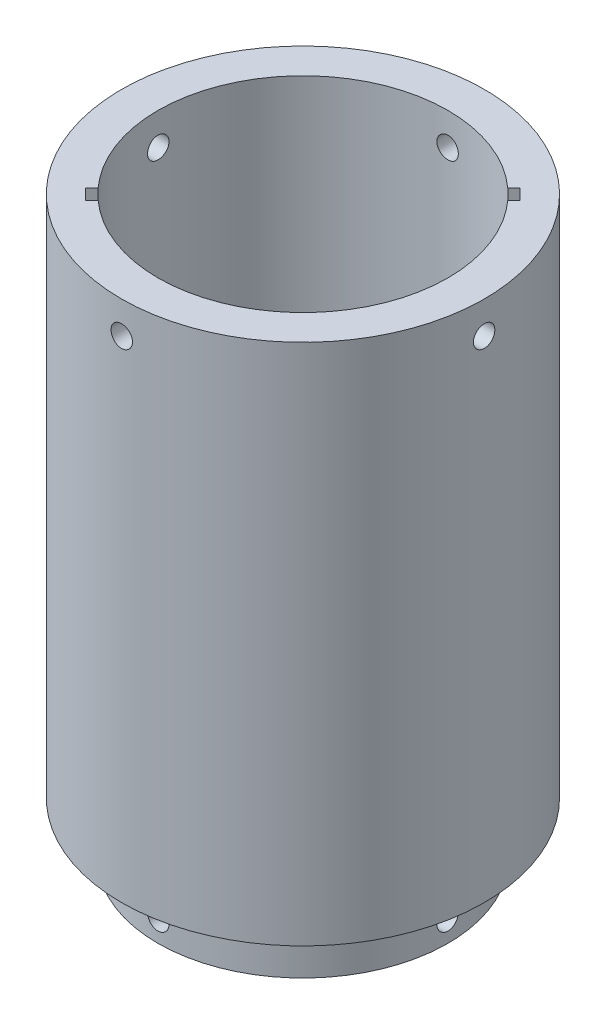
from build123d import *

# Parameters (mm, degrees)
SKETCH1_R               = 33.85
BOSS_EXTRUDE1_DEPTH     = 12.5
SKETCH2_R               = 2.5
CUT_EXTRUDE1_DEPTH      = 34.85
CUT_EXTRUDE1_DEPTH_BACK = 34.85
SKETCH3_R               = 2.5
CUT_EXTRUDE2_DEPTH      = 34.8500001
CUT_EXTRUDE2_DEPTH_BACK = 34.8500001
SKETCH4_R               = 42.35
BOSS_EXTRUDE2_DEPTH     = 2
SKETCH5_R               = 42.35
SKETCH5_R_2             = 33.85
BOSS_EXTRUDE3_DEPTH     = 120
SKETCH6_R               = 2.5
CUT_EXTRUDE3_DEPTH      = 43.35
CUT_EXTRUDE3_DEPTH_BACK = 43.35
SKETCH7_R               = 2.5
CUT_EXTRUDE4_DEPTH      = 43.3500001
CUT_EXTRUDE4_DEPTH_BACK = 43.3500001
CUT_EXTRUDE5_DEPTH      = 120


with BuildPart() as part:
    # Sketch1 → Boss-Extrude1 (new body)
    with BuildSketch(Plane(origin=(0, 0, 0), x_dir=(1, 0, 0), z_dir=(0, 1, 0))):
        Circle(SKETCH1_R)
    extrude(amount=BOSS_EXTRUDE1_DEPTH)

    # Sketch2 → Cut-Extrude1 (cut, two sides)
    with BuildSketch(Plane(origin=(0, 0, 0), x_dir=(0, 0, -1), z_dir=(1, 0, 0))) as cut_extrude1_sk:
        with Locations((0, 5)):
            Circle(SKETCH2_R)
    extrude(amount=CUT_EXTRUDE1_DEPTH, mode=Mode.SUBTRACT)
    extrude(cut_extrude1_sk.sketch, amount=-CUT_EXTRUDE1_DEPTH_BACK, mode=Mode.SUBTRACT)

    # Sketch3 → Cut-Extrude2 (cut, two sides)
    with BuildSketch(Plane.XY) as cut_extrude2_sk:
        with Locations((0, 5)):
            Circle(SKETCH3_R)
    extrude(amount=CUT_EXTRUDE2_DEPTH, mode=Mode.SUBTRACT)
    extrude(cut_extrude2_sk.sketch, amount=-CUT_EXTRUDE2_DEPTH_BACK, mode=Mode.SUBTRACT)

    # Sketch4 → Boss-Extrude2 (add)
    with BuildSketch(Plane(origin=(0, 12.5, 0), x_dir=(1, 0, 0), z_dir=(0, 1, 0))):
        Circle(SKETCH4_R)
    extrude(amount=BOSS_EXTRUDE2_DEPTH)

    # Sketch5 → Boss-Extrude3 (add)
    with BuildSketch(Plane(origin=(0, 14.5, 0), x_dir=(1, 0, 0), z_dir=(0, 1, 0))):
        Circle(SKETCH5_R)
        Circle(SKETCH5_R_2, mode=Mode.SUBTRACT)
    extrude(amount=BOSS_EXTRUDE3_DEPTH)

    # Sketch6 → Cut-Extrude3 (cut, two sides)
    with BuildSketch(Plane(origin=(0, 0, 0), x_dir=(0, 0, -1), z_dir=(1, 0, 0))) as cut_extrude3_sk:
        with Locations((0, 127)):
            Circle(SKETCH6_R)
    extrude(amount=CUT_EXTRUDE3_DEPTH, mode=Mode.SUBTRACT)
    extrude(cut_extrude3_sk.sketch, amount=-CUT_EXTRUDE3_DEPTH_BACK, mode=Mode.SUBTRACT)

    # Sketch7 → Cut-Extrude4 (cut, two sides)
    with BuildSketch(Plane.XY) as cut_extrude4_sk:
        with Locations((0, 127)):
            Circle(SKETCH7_R)
    extrude(amount=CUT_EXTRUDE4_DEPTH, mode=Mode.SUBTRACT)
    extrude(cut_extrude4_sk.sketch, amount=-CUT_EXTRUDE4_DEPTH_BACK, mode=Mode.SUBTRACT)

    # Sketch9 → Cut-Extrude5 (cut)
    with BuildSketch(Plane(origin=(0, 134.5, 0), x_dir=(1, 0, 0), z_dir=(0, 1, 0))):
        Polygon((24.112341238, 26.587214973), (-26.587214973, -24.112341238), (-24.112341238, -26.587214973), (26.587214973, 24.112341238), align=None)
    extrude(amount=-CUT_EXTRUDE5_DEPTH, mode=Mode.SUBTRACT)


solid = part.part
